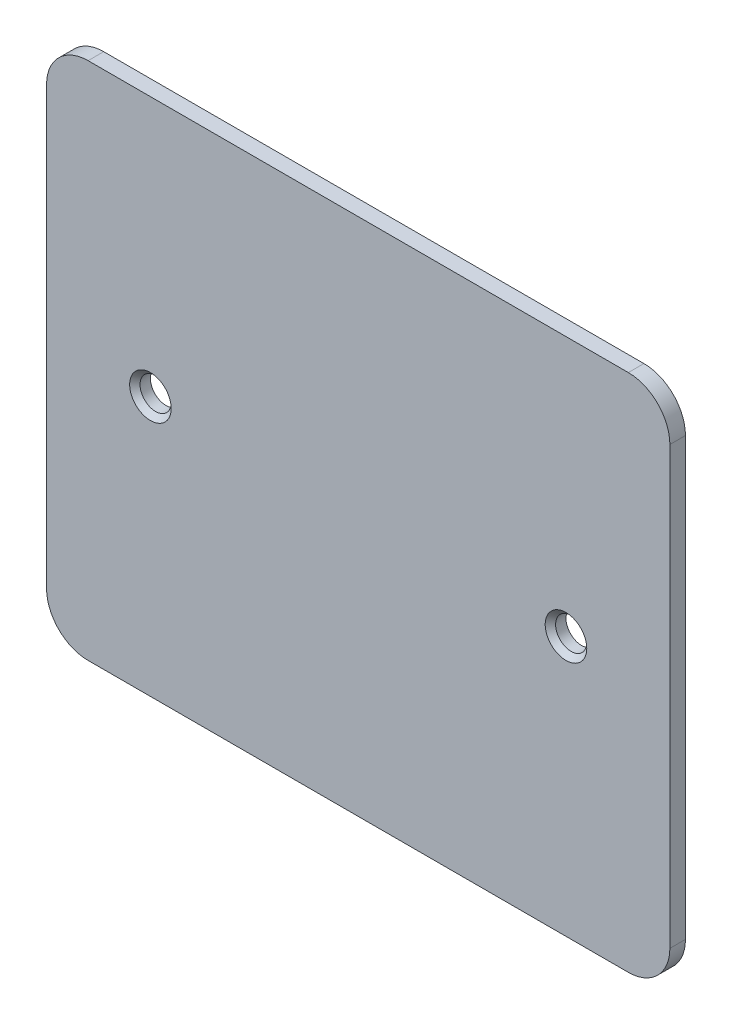
from build123d import *

# Parameters (mm, degrees)
ESQUISSE1_W      = 60
ESQUISSE1_H      = 50
ESQUISSE1_R      = 1.5
EXTRUSION1_DEPTH = 1.5
CHANFREIN1_SIZE  = 0.5
CONG_1_R         = 4


with BuildPart() as part:
    # Esquisse1 → Extrusion1 (new body)
    with BuildSketch(Plane.XY):
        with Locations((-30, 25)):
            Rectangle(ESQUISSE1_W, ESQUISSE1_H)
        with Locations((-50, 25)):
            Circle(ESQUISSE1_R, mode=Mode.SUBTRACT)
        with Locations((-10, 25)):
            Circle(ESQUISSE1_R, mode=Mode.SUBTRACT)
    extrude(amount=EXTRUSION1_DEPTH)

    # Chanfrein1
    chanfrein1_edges = [part.edges().sort_by_distance(p)[0] for p in [
        (-51.5, 25, 1.5),
        (-11.5, 25, 1.5),
    ]]
    chamfer(chanfrein1_edges, length=CHANFREIN1_SIZE)

    # Congé1
    cong_1_edges = [part.edges().sort_by_distance(p)[0] for p in [
        (0, 0, 0.75),
        (-60, 0, 0.75),
        (-60, 50, 0.75),
        (0, 50, 0.75),
    ]]
    fillet(cong_1_edges, radius=CONG_1_R)


solid = part.part
